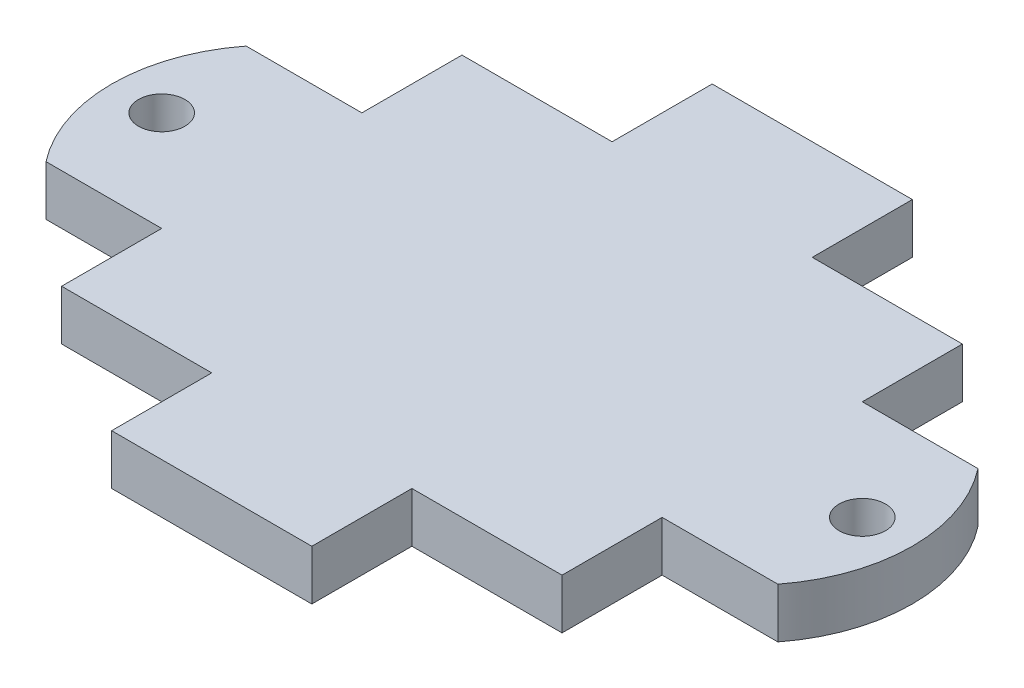
from build123d import *

# Parameters (mm, degrees)
BOSS_EXTRUDE1_DEPTH       = 3.175
F_4_CLEARANCE_HOLE1_D     = 2.9464
F_4_CLEARANCE_HOLE1_DEPTH = 6.35
F_4_CLEARANCE_HOLE1_TIP   = 0.885187864


with BuildPart() as part:
    # Sketch1 → Boss-Extrude1 (new body)
    with BuildSketch(Plane(origin=(0, 0, 0), x_dir=(1, 0, 0), z_dir=(0, 1, 0))):
        with BuildLine():
            Line((-15.875, 12.7), (-6.35, 12.7))
            Line((-6.35, 12.7), (-6.35, 19.05))
            Line((-6.35, 19.05), (6.35, 19.05))
            Line((6.35, 19.05), (6.35, 12.7))
            Line((6.35, 12.7), (15.875, 12.7))
            Line((15.875, 12.7), (15.875, 6.35))
            Line((15.875, 6.35), (19.05, 6.35))
            Line((19.05, 6.35), (23.21476717, 6.35))
            ThreePointArc((23.21476717, 6.35), (25.4, 0), (23.21476717, -6.35))
            Line((23.21476717, -6.35), (19.05, -6.35))
            Line((19.05, -6.35), (15.875, -6.35))
            Line((15.875, -6.35), (15.875, -12.7))
            Line((15.875, -12.7), (6.35, -12.7))
            Line((6.35, -12.7), (6.35, -19.05))
            Line((6.35, -19.05), (-6.35, -19.05))
            Line((-6.35, -19.05), (-6.35, -12.7))
            Line((-6.35, -12.7), (-15.875, -12.7))
            Line((-15.875, -12.7), (-15.875, -6.35))
            Line((-15.875, -6.35), (-19.05, -6.35))
            Line((-19.05, -6.35), (-23.21476717, -6.35))
            ThreePointArc((-23.21476717, -6.35), (-25.4, 0), (-23.21476717, 6.35))
            Line((-23.21476717, 6.35), (-19.05, 6.35))
            Line((-19.05, 6.35), (-15.875, 6.35))
            Line((-15.875, 6.35), (-15.875, 12.7))
        make_face()
    extrude(amount=BOSS_EXTRUDE1_DEPTH)

    # #4 Clearance Hole1
    with Locations(Plane(origin=(0, 3.175, 0), x_dir=(-1, 0, 0), z_dir=(0, 1, 0))):
        with Locations((-22.225, 0), (22.225, 0)):
            Hole(F_4_CLEARANCE_HOLE1_D / 2, depth=F_4_CLEARANCE_HOLE1_DEPTH)
            with Locations((0, 0, -(F_4_CLEARANCE_HOLE1_DEPTH + F_4_CLEARANCE_HOLE1_TIP / 2))):  # 118° drill point
                Cone(0, F_4_CLEARANCE_HOLE1_D / 2, F_4_CLEARANCE_HOLE1_TIP, mode=Mode.SUBTRACT)


solid = part.part
